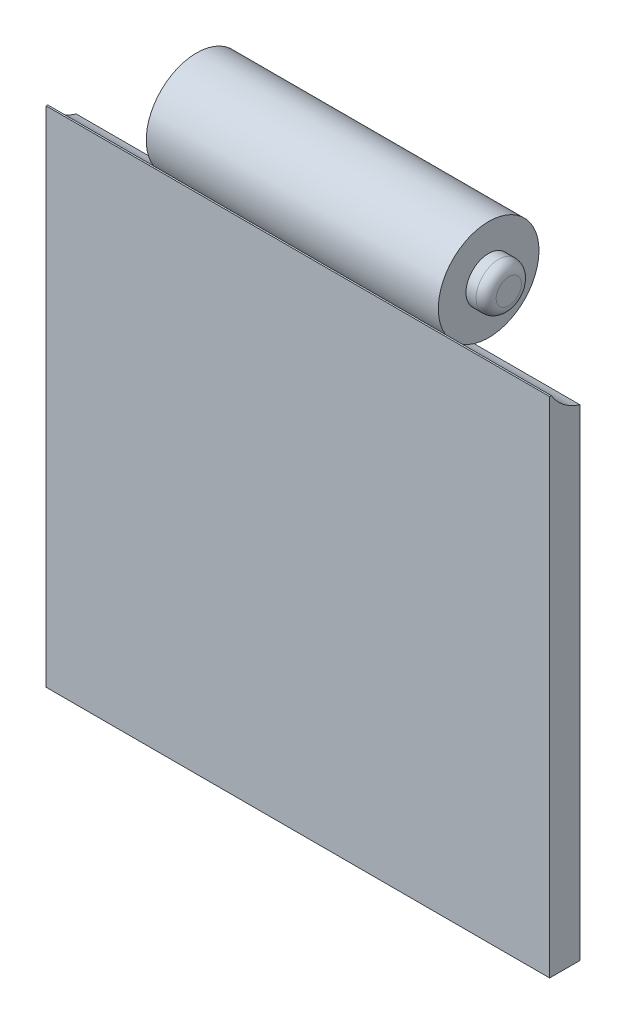
from build123d import *

# Parameters (mm, degrees)
SKETCH1_W                = 50
SKETCH1_H                = 3
BOSS_EXTRUDE1_DEPTH      = 50
SKETCH2_R                = 5
BOSS_EXTRUDE2_DEPTH      = 14.5
BOSS_EXTRUDE2_DEPTH_BACK = 14.5
SKETCH3_R                = 2.25
BOSS_EXTRUDE3_DEPTH      = 2
FILLET2_R                = 1
FILLET2_OF_MIRROR1_R     = 1
CUT_EXTRUDE1_DEPTH       = 11.5


with BuildPart() as part:
    # Sketch1 → Boss-Extrude1 (new body)
    with BuildSketch(Plane(origin=(0, 0, 0), x_dir=(1, 0, 0), z_dir=(0, 1, 0))):
        Rectangle(SKETCH1_W, SKETCH1_H)
    extrude(amount=BOSS_EXTRUDE1_DEPTH)

    # Sketch2 → Boss-Extrude2 (add, two sides)
    with BuildSketch(Plane(origin=(0, 0, 0), x_dir=(0, 0, -1), z_dir=(1, 0, 0))) as boss_extrude2_sk:
        with Locations((2.940369627, 52.589467232)):
            Circle(SKETCH2_R)
    extrude(amount=BOSS_EXTRUDE2_DEPTH)
    extrude(boss_extrude2_sk.sketch, amount=-BOSS_EXTRUDE2_DEPTH_BACK)

    # Sketch3 → Boss-Extrude3 (add)
    with BuildSketch(Plane(origin=(14.5, 0, 0), x_dir=(0, 0, -1), z_dir=(1, 0, 0))):
        with Locations((2.940369627, 52.589467232)):
            Circle(SKETCH3_R)
    boss_extrude3 = extrude(amount=BOSS_EXTRUDE3_DEPTH)

    # Fillet2
    fillet2_edges = [part.edges().sort_by_distance(p)[0] for p in [
        (16.5, 52.589467232, -0.690369627),
    ]]
    fillet(fillet2_edges, radius=FILLET2_R)

    # Mirror1: Boss-Extrude3 across plane
    add(boss_extrude3.mirror(Plane(origin=(0, 0, 0), x_dir=(0, 0, 1), z_dir=(1, 0, 0))))

    # Fillet2 of Mirror1
    fillet2_of_mirror1_edges = [part.edges().sort_by_distance(p)[0] for p in [
        (-16.5, 52.589467232, -0.690369627),
    ]]
    fillet(fillet2_of_mirror1_edges, radius=FILLET2_OF_MIRROR1_R)

    # Sketch4 → Cut-Extrude1 (cut, through all)
    with BuildSketch(Plane(origin=(14.5, 0, 0), x_dir=(0, 0, -1), z_dir=(1, 0, 0))):
        with BuildLine():
            Line((1.5, 50), (1.5, 47.801426366))
            ThreePointArc((1.5, 47.801426366), (-0.122497577, 48.637398851), (-1.336856045, 50))
            Line((-1.336856045, 50), (1.5, 50))
        make_face()
    cut_extrude1 = extrude(amount=CUT_EXTRUDE1_DEPTH, mode=Mode.SUBTRACT)

    # Mirror2: Cut-Extrude1 across plane
    add(cut_extrude1.mirror(Plane(origin=(0, 0, 0), x_dir=(0, 0, 1), z_dir=(1, 0, 0))), mode=Mode.SUBTRACT)


solid = part.part
